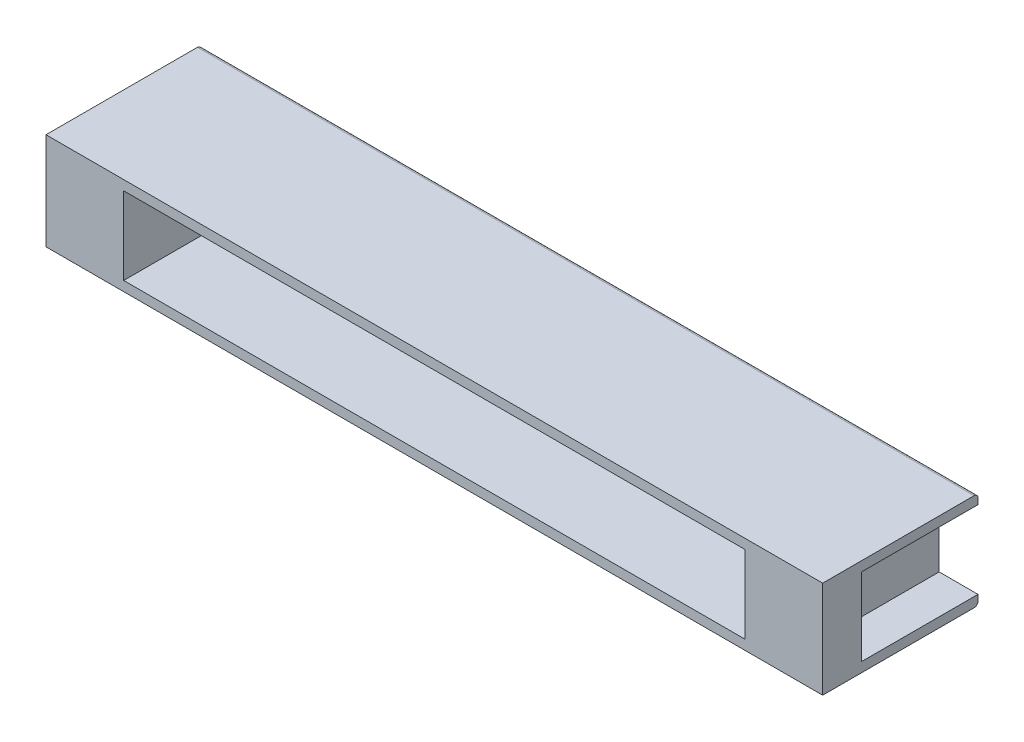
from build123d import *

# Parameters (mm, degrees)
SKETCH1_W           = 20
SKETCH1_H           = 2.5
BOSS_EXTRUDE1_DEPTH = 4
SKETCH2_W           = 1
SKETCH2_H           = 2
SKETCH2_W_2         = 16
CUT_EXTRUDE1_DEPTH  = 4
SKETCH3_W           = 16
SKETCH3_H           = 2
BOSS_EXTRUDE2_DEPTH = 1
BOSS_EXTRUDE3_DEPTH = 0.5
LPATTERN1_COUNT     = 15
LPATTERN1_PITCH     = 1
SKETCH5_W           = 1
SKETCH5_H           = 2
BOSS_EXTRUDE4_DEPTH = 1
FILLET1_R           = 0.1


with BuildPart() as part:
    # Sketch1 → Boss-Extrude1 (new body)
    with BuildSketch(Plane.XY):
        Rectangle(SKETCH1_W, SKETCH1_H)
    extrude(amount=BOSS_EXTRUDE1_DEPTH)

    # Sketch2 → Cut-Extrude1 (cut)
    with BuildSketch(Plane.XY.offset(4)):
        with Locations((-9.5, 0)):
            Rectangle(SKETCH2_W, SKETCH2_H)
        with Locations((9.5, 0)):
            Rectangle(SKETCH2_W, SKETCH2_H)
        Rectangle(SKETCH2_W_2, SKETCH2_H)
    extrude(amount=-CUT_EXTRUDE1_DEPTH, mode=Mode.SUBTRACT)

    # Sketch3 → Boss-Extrude2 (add)
    with BuildSketch(Plane(origin=(0, 0, 0), x_dir=(-1, 0, 0), z_dir=(0, 0, -1))):
        Rectangle(SKETCH3_W, SKETCH3_H)
    extrude(amount=-BOSS_EXTRUDE2_DEPTH)

    # Sketch4 → Boss-Extrude3 (add)
    with BuildSketch(Plane(origin=(6.75, 0, 0), x_dir=(0, 0, -1), z_dir=(1, 0, 0))):
        with BuildLine():
            Line((0, 0.230197845), (0.567789533, 0.230197845))
            ThreePointArc((0.567789533, 0.230197845), (0.810876854, 0.167128679), (0.992638918, -0.006167939))
            Line((0.992638918, -0.006167939), (1.307539867, -0.513634217))
            ThreePointArc((1.307539867, -0.513634217), (1.48930193, -0.686930834), (1.732389252, -0.75))
            Line((1.732389252, -0.75), (1.9, -0.75))
            ThreePointArc((1.9, -0.75), (1.970710678, -0.779289322), (2, -0.85))
            Line((2, -0.85), (2, -1.15))
            ThreePointArc((2, -1.15), (1.970710678, -1.220710678), (1.9, -1.25))
            Line((1.9, -1.25), (1.454213277, -1.25))
            ThreePointArc((1.454213277, -1.25), (1.211125955, -1.186930834), (1.029363892, -1.013634217))
            Line((1.029363892, -1.013634217), (0.714462943, -0.506167939))
            ThreePointArc((0.714462943, -0.506167939), (0.532700879, -0.332871321), (0.289613558, -0.269802155))
            Line((0.289613558, -0.269802155), (0, -0.269802155))
            Line((0, -0.269802155), (0, 0.230197845))
        make_face()
    boss_extrude3 = extrude(amount=BOSS_EXTRUDE3_DEPTH)

    # LPattern1: Boss-Extrude3 ×15
    with Locations(*[(-i * LPATTERN1_PITCH, 0, 0) for i in range(1, LPATTERN1_COUNT)]):
        add(boss_extrude3)

    # Sketch5 → Boss-Extrude4 (add)
    with BuildSketch(Plane.XY.offset(4)):
        with Locations((-9.5, 0)):
            Rectangle(SKETCH5_W, SKETCH5_H)
        with Locations((9.5, 0)):
            Rectangle(SKETCH5_W, SKETCH5_H)
    extrude(amount=-BOSS_EXTRUDE4_DEPTH)

    # Fillet1
    fillet1_edges = [part.edges().sort_by_distance(p)[0] for p in [
        (0, -1.25, 0),
        (0, 1.25, 0),
    ]]
    fillet(fillet1_edges, radius=FILLET1_R)


solid = part.part
